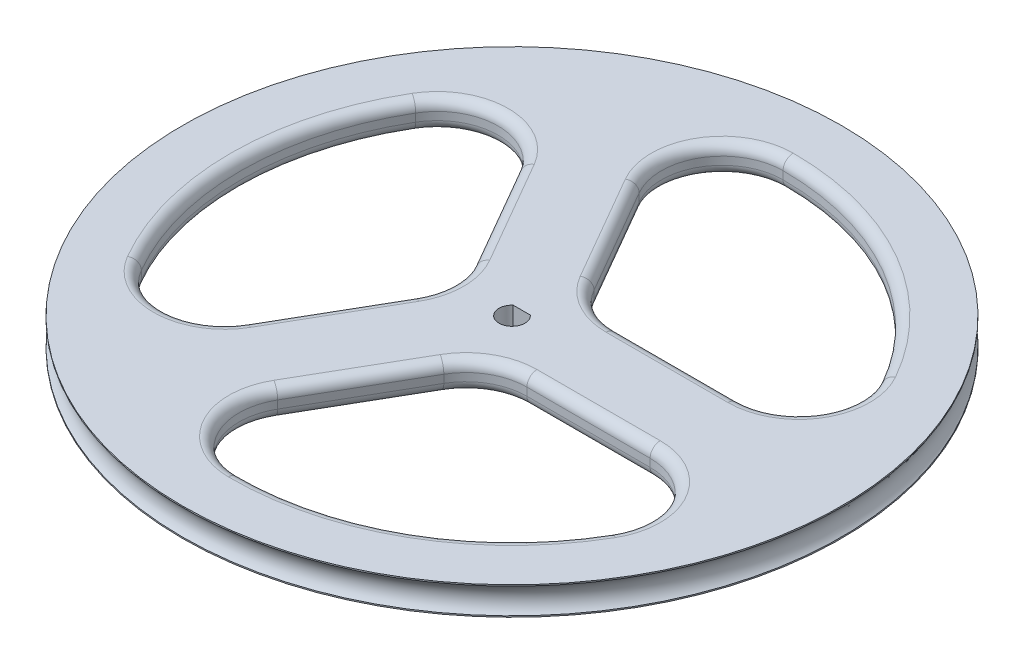
from build123d import *

# Parameters (mm, degrees)
SKETCH1_R                = 41.275
BOSS_EXTRUDE1_DEPTH      = 3.5306
CUT_EXTRUDE1_DEPTH       = 3.5306
FILLET2_R                = 7.62
FILLET3_R                = 1.27
CIRPATTERN3_COUNT        = 3
FILLET2_OF_CIRPATTERN3_R = 7.62
FILLET3_OF_CIRPATTERN3_R = 1.27
CUT_EXTRUDE2_DEPTH       = 3.5306
SKETCH4_R                = 2.213695011


with BuildPart() as part:
    # Sketch1 → Boss-Extrude1 (new body)
    with BuildSketch(Plane(origin=(0, 0, 0), x_dir=(1, 0, 0), z_dir=(0, 1, 0))):
        Circle(SKETCH1_R)
    extrude(amount=BOSS_EXTRUDE1_DEPTH)

    # Sketch2 → Cut-Extrude1 (cut)
    with BuildSketch(Plane(origin=(0, 0, 0), x_dir=(1, 0, 0), z_dir=(0, 1, 0))):
        with BuildLine():
            Line((3.293968832, 5.375948382), (-11.963907018, 31.803364569))
            ThreePointArc((-11.963907018, 31.803364569), (17.061820738, 29.385087071), (33.55127789, 5.375948382))
            Line((33.55127789, 5.375948382), (3.293968832, 5.375948382))
        make_face()
    cut_extrude1 = extrude(amount=CUT_EXTRUDE1_DEPTH, mode=Mode.SUBTRACT)

    # Fillet2
    fillet2_edges = [part.edges().sort_by_distance(p)[0] for p in [
        (3.293968832, 1.7653, -5.375948382),
        (33.55127789, 1.7653, -5.375948382),
        (-11.963907018, 1.7653, -31.803364569),
    ]]
    fillet(fillet2_edges, radius=FILLET2_R)

    # Fillet3
    fillet3_edges = [part.edges().sort_by_distance(p)[0] for p in [
        (-2.763384421, 0, -15.867591974),
        (-2.763384421, 3.5306, -15.867591974),
        (15.313108455, 0, -5.375948382),
        (15.313108455, 3.5306, -5.375948382),
        (17.09538989, 0, -29.365570207),
        (17.09538989, 3.5306, -29.365570207),
        (3.883377883, 0, -6.396834805),
        (3.883377883, 3.5306, -6.396834805),
        (-6.622616719, 0, -30.166491423),
        (-6.622616719, 3.5306, -30.166491423),
        (29.516606991, 0, -9.159491763),
        (29.516606991, 3.5306, -9.159491763),
    ]]
    fillet(fillet3_edges, radius=FILLET3_R)

    # CirPattern3: Cut-Extrude1 ×3 about axis
    cirpattern3_axis = Axis((0, 0, 0), (0, 1, 0))
    for i in range(1, CIRPATTERN3_COUNT):
        add(cut_extrude1.rotate(cirpattern3_axis, i * 360 / CIRPATTERN3_COUNT), mode=Mode.SUBTRACT)

    # Fillet2 of CirPattern3
    fillet2_of_cirpattern3_edges = [part.edges().sort_by_distance(p)[0] for p in [
        (-6.302692284, 1.7653, -0.164686497),
        (-21.431346813, 1.7653, -26.368284791),
        (-21.560568134, 1.7653, 26.262729691),
        (3.008723452, 1.7653, 5.540634879),
        (-12.119931077, 1.7653, 31.744233173),
        (33.524475152, 1.7653, 5.540634879),
    ]]
    fillet(fillet2_of_cirpattern3_edges, radius=FILLET2_OF_CIRPATTERN3_R)

    # Fillet3 of CirPattern3
    fillet3_of_cirpattern3_edges = [part.edges().sort_by_distance(p)[0] for p in [
        (-12.360045536, 0, 10.326957096),
        (-12.360045536, 3.5306, 10.326957096),
        (-12.312262095, 0, -10.573566742),
        (-12.312262095, 3.5306, -10.573566742),
        (-33.979024741, 0, -0.122256829),
        (-33.979024741, 3.5306, -0.122256829),
        (-7.481510386, 0, -0.164686497),
        (-7.481510386, 3.5306, -0.164686497),
        (-22.813639556, 0, 20.81860003),
        (-22.813639556, 3.5306, 20.81860003),
        (-22.690656048, 0, -20.982385606),
        (-22.690656048, 3.5306, -20.982385606),
        (15.123429957, 0, 5.540634879),
        (15.123429957, 3.5306, 5.540634879),
        (-3.000846359, 0, 15.949515123),
        (-3.000846359, 3.5306, 15.949515123),
        (16.883634851, 0, 29.487827036),
        (16.883634851, 3.5306, 29.487827036),
        (3.598132503, 0, 6.561521302),
        (3.598132503, 3.5306, 6.561521302),
        (29.436256275, 0, 9.347891394),
        (29.436256275, 3.5306, 9.347891394),
        (-6.825950943, 0, 30.141877369),
        (-6.825950943, 3.5306, 30.141877369),
    ]]
    fillet(fillet3_of_cirpattern3_edges, radius=FILLET3_OF_CIRPATTERN3_R)

    # Sketch5 → Cut-Extrude2 (cut)
    with BuildSketch(Plane(origin=(0, 0, 0), x_dir=(1, 0, 0), z_dir=(0, 1, 0))):
        with BuildLine():
            Line((-1.075233333, 1.2192), (1.075233333, 1.2192))
            ThreePointArc((1.075233333, 1.2192), (0, -1.6256), (-1.075233333, 1.2192))
        make_face()
    extrude(amount=CUT_EXTRUDE2_DEPTH, mode=Mode.SUBTRACT)

    # Sketch4 → Cut-Revolve3 (revolve, cut)
    with BuildSketch(Plane(origin=(0, 0, 0), x_dir=(0, 0, -1), z_dir=(1, 0, 0))):
        with Locations((42.799700103, 1.7653)):
            Circle(SKETCH4_R)
    revolve(axis=Axis((0, 0, 0), (0, 1, 0)), mode=Mode.SUBTRACT)


solid = part.part
